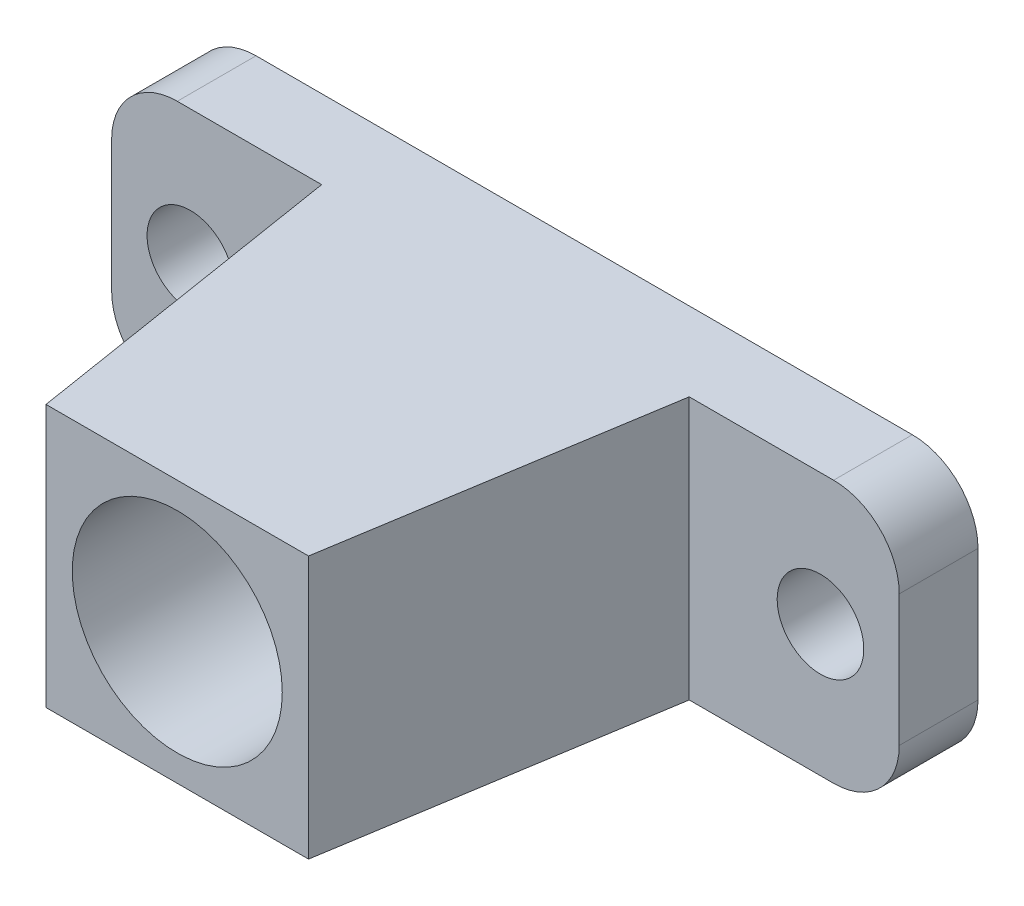
from build123d import *

# Parameters (mm, degrees)
SKETCH_1_R          = 3.3
EXTRUDE_1_DEPTH     = 6
EXTRUDE_3_DEPTH     = 20
SKETCH_3_R          = 8
CUT_EXTRUDE_1_DEPTH = 32


with BuildPart() as part:
    # 草图1 → 凸台-拉伸1 (new body)
    with BuildSketch(Plane.XY):
        with BuildLine():
            Line((25, 10), (-25, 10))
            ThreePointArc((-25, 10), (-28.535533906, 8.535533906), (-30, 5))
            Line((-30, 5), (-30, -5))
            ThreePointArc((-30, -5), (-28.535533906, -8.535533906), (-25, -10))
            Line((-25, -10), (25, -10))
            ThreePointArc((25, -10), (28.535533906, -8.535533906), (30, -5))
            Line((30, -5), (30, 5))
            ThreePointArc((30, 5), (28.535533906, 8.535533906), (25, 10))
        make_face()
        with Locations((-24, 0)):
            Circle(SKETCH_1_R, mode=Mode.SUBTRACT)
        with Locations((24, 0)):
            Circle(SKETCH_1_R, mode=Mode.SUBTRACT)
    extrude(amount=EXTRUDE_1_DEPTH)

    # 草图2 → 凸台-拉伸3 (add)
    with BuildSketch(Plane(origin=(0, 10, 0), x_dir=(1, 0, 0), z_dir=(0, 1, 0))):
        Polygon((14, -6), (-14, -6), (-10, -31), (10, -31), align=None)
    extrude(amount=-EXTRUDE_3_DEPTH)

    # 草图3 → 切除-拉伸1 (cut, through all)
    with BuildSketch(Plane.XY.offset(31)):
        Circle(SKETCH_3_R)
    extrude(amount=-CUT_EXTRUDE_1_DEPTH, mode=Mode.SUBTRACT)


solid = part.part
